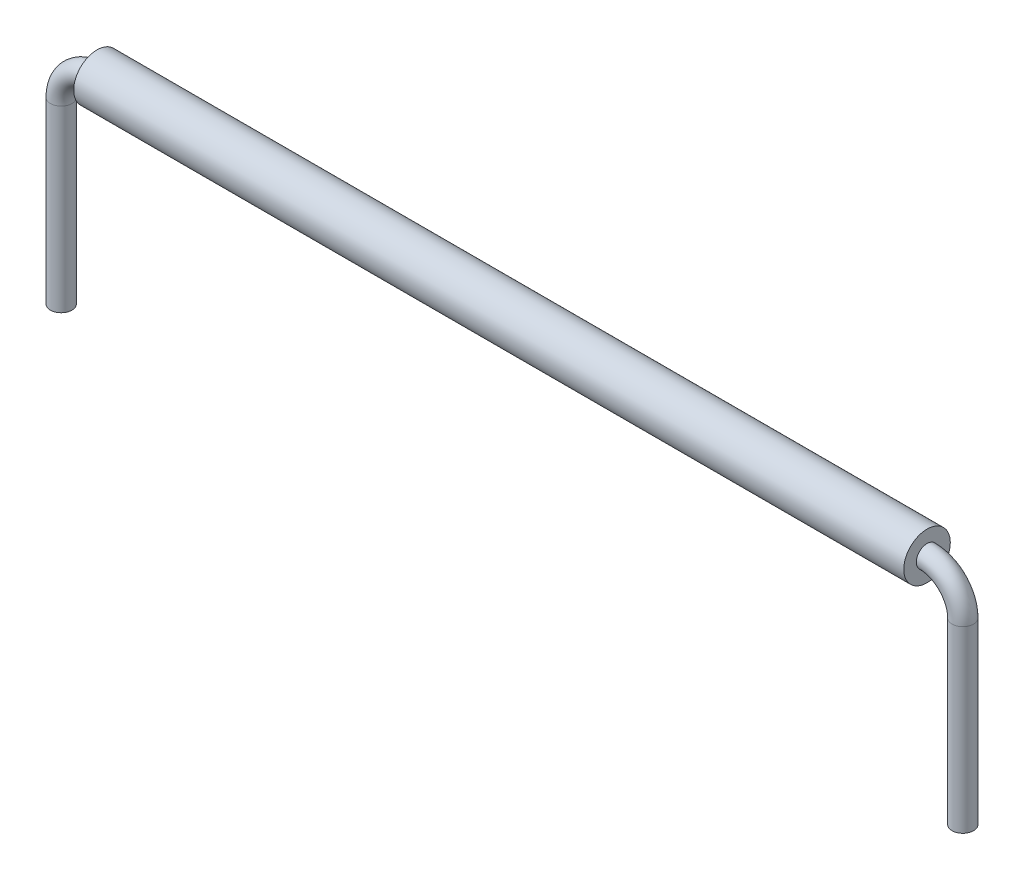
from build123d import *

# Parameters (mm, degrees)
SKETCH2_R                = 0.3
SKETCH3_R                = 0.65
SKETCH3_R_2              = 0.3
BOSS_EXTRUDE1_DEPTH      = 11.596
BOSS_EXTRUDE1_DEPTH_BACK = 11.596


with BuildPart() as part:
    # Sweep1: sweep along a path in Sketch1
    with BuildLine(Plane.XY) as sweep1_path:
        Line((-12.596, -6), (-12.596, -1))
        ThreePointArc((-12.596, -1), (-12.303106781, -0.292893219), (-11.596, 0))
        Line((-11.596, 0), (11.596, 0))
        ThreePointArc((11.596, 0), (12.303106781, -0.292893219), (12.596, -1))
        Line((12.596, -1), (12.596, -6))
    # Sketch2 → Sweep1 (sweep)
    with BuildSketch(Plane(origin=(0, 0, 0), x_dir=(0, 0, -1), z_dir=(1, 0, 0))):
        Circle(SKETCH2_R)
    sweep(path=sweep1_path.line)


with BuildPart() as body_2:
    # Sketch3 → Boss-Extrude1 (new body, two sides)
    with BuildSketch(Plane(origin=(0, 0, 0), x_dir=(0, 0, -1), z_dir=(1, 0, 0))) as boss_extrude1_sk:
        Circle(SKETCH3_R)
        Circle(SKETCH3_R_2, mode=Mode.SUBTRACT)
    extrude(amount=BOSS_EXTRUDE1_DEPTH)
    extrude(boss_extrude1_sk.sketch, amount=-BOSS_EXTRUDE1_DEPTH_BACK)


solid = Compound([part.part, body_2.part])
